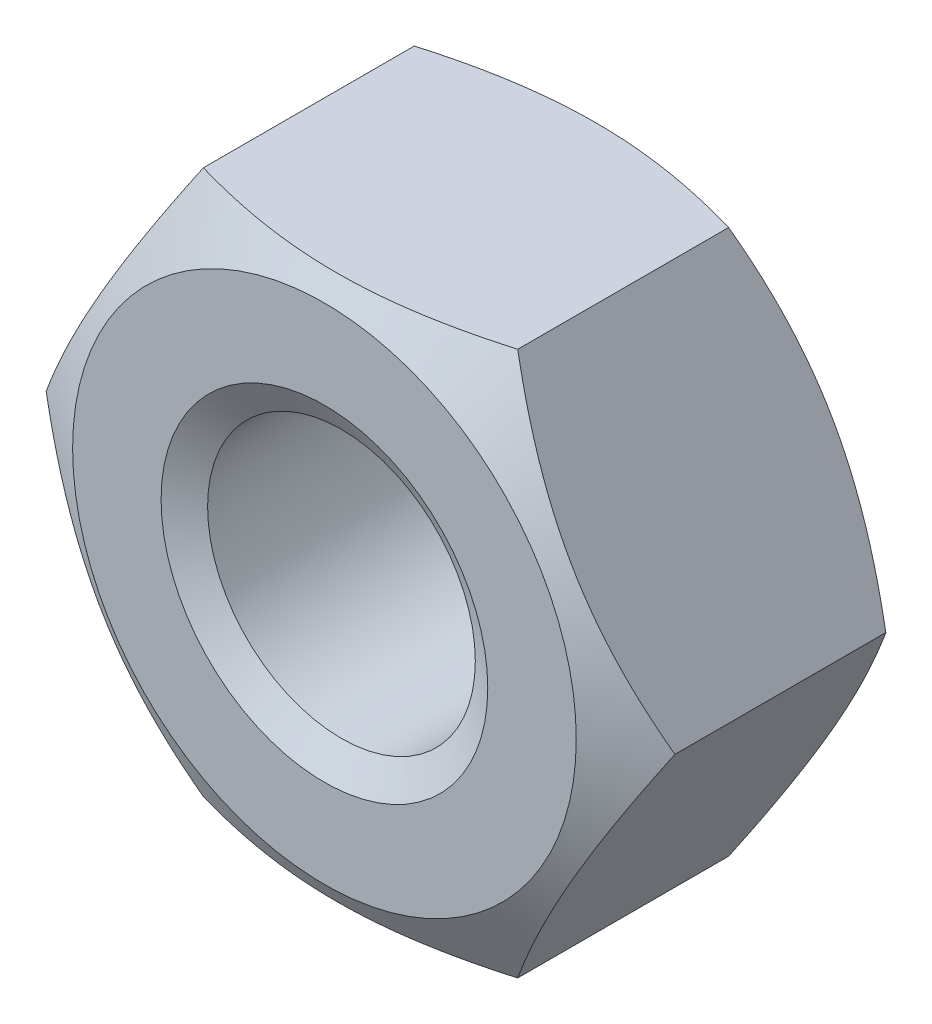
from build123d import *

# Parameters (mm, degrees)
SKETCH1_R               = 2.4585
BASENUT_DEPTH           = 5.2
ENDCHAMFER_SIZE         = 0.5415
ENDCHAMFER_SIZE2        = 0.312635171
ENDCHAMFER_PART_2_SIZE  = 0.5415
ENDCHAMFER_PART_2_SIZE2 = 0.312635171


with BuildPart() as part:
    # Sketch1 → BaseNut (new body)
    with BuildSketch(Plane.XY):
        Polygon((5.773502692, 0), (2.886751346, 5), (-2.886751346, 5), (-5.773502692, 0), (-2.886751346, -5), (2.886751346, -5), align=None)
        Circle(SKETCH1_R, mode=Mode.SUBTRACT)
    extrude(amount=-BASENUT_DEPTH)

    # Sketch2 → Double-Chamfer (revolve, cut)
    with BuildSketch(Plane(origin=(0, 0, 0), x_dir=(1, 0, 0), z_dir=(0, 1, 0))):
        Polygon((-5.773502692, 5.2), (-4.625, 5.2), (-5.773502692, 4.536911662), align=None)
        Polygon((-5.773502692, 0.663088338), (-5.773502692, 0), (-4.625, 0), align=None)
    revolve(axis=Axis((0, 0, -3.375940562), (0, 0, 1)), mode=Mode.SUBTRACT)

    # EndChamfer
    endchamfer_edges = [part.edges().sort_by_distance(p)[0] for p in [
        (-2.4585, 0, -5.2),
    ]]
    endchamfer_side = [part.faces().sort_by_distance(p)[0] for p in [
        (-2.4585, 0, -2.6),
    ]]
    chamfer(endchamfer_edges, length=ENDCHAMFER_SIZE, length2=ENDCHAMFER_SIZE2, reference=endchamfer_side[0])

    # EndChamfer part 2
    endchamfer_part_2_edges = [part.edges().sort_by_distance(p)[0] for p in [
        (-2.4585, 0, 0),
    ]]
    endchamfer_part_2_side = [part.faces().sort_by_distance(p)[0] for p in [
        (4.494185245, 0, 0),
    ]]
    chamfer(endchamfer_part_2_edges, length=ENDCHAMFER_PART_2_SIZE, length2=ENDCHAMFER_PART_2_SIZE2, reference=endchamfer_part_2_side[0])


solid = part.part
